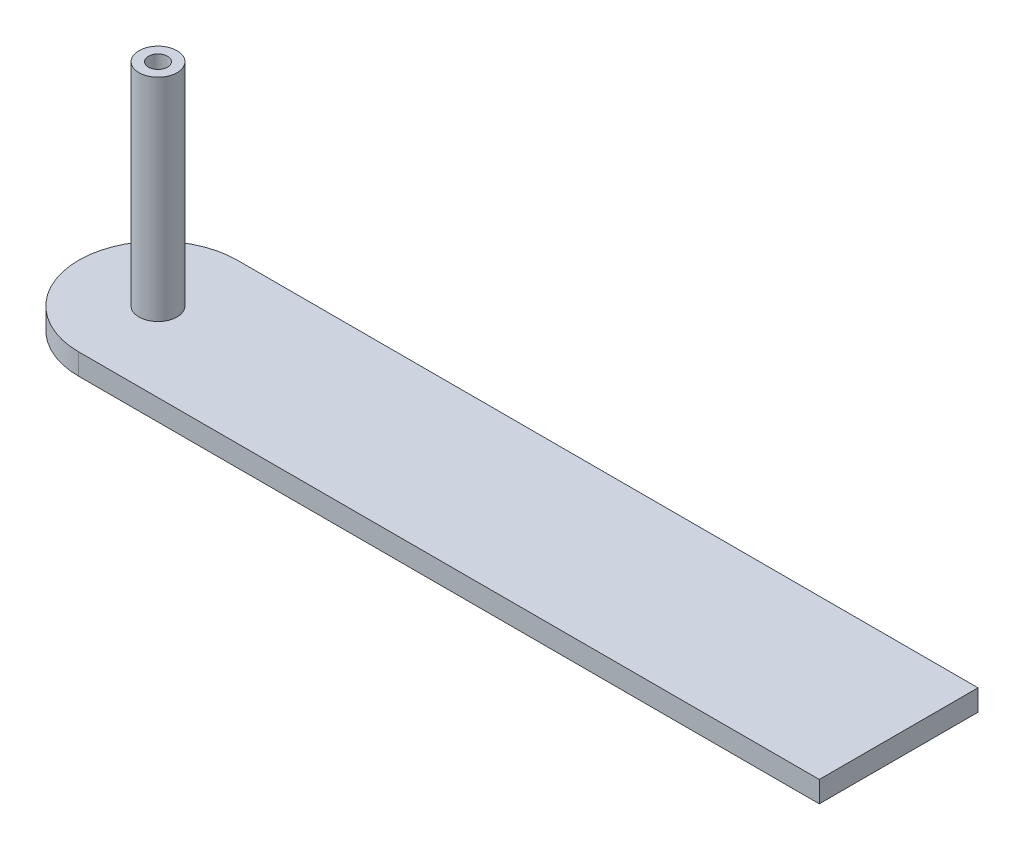
from build123d import *

# Parameters (mm, degrees)
SKETCH1_W           = 70
SKETCH1_H           = 15
BOSS_EXTRUDE1_DEPTH = 2
BOSS_EXTRUDE2_START = -2
SKETCH2_R           = 7.5
BOSS_EXTRUDE2_DEPTH = 2
SKETCH3_R           = 1.8
BOSS_EXTRUDE3_DEPTH = 20
SKETCH6_R           = 0.9
CUT_EXTRUDE1_DEPTH  = 6.5


with BuildPart() as part:
    # Sketch1 → Boss-Extrude1 (new body)
    with BuildSketch(Plane(origin=(0, 0, 0), x_dir=(1, 0, 0), z_dir=(0, 1, 0))):
        with Locations((35, 7.5)):
            Rectangle(SKETCH1_W, SKETCH1_H)
    extrude(amount=BOSS_EXTRUDE1_DEPTH)

    # Sketch2 → Boss-Extrude2 (add)
    with BuildSketch(Plane(origin=(0, 2, 0), x_dir=(1, 0, 0), z_dir=(0, 1, 0)).offset(BOSS_EXTRUDE2_START)):
        with Locations((0, 7.5)):
            Circle(SKETCH2_R)
    extrude(amount=BOSS_EXTRUDE2_DEPTH)

    # Sketch3 → Boss-Extrude3 (add)
    with BuildSketch(Plane(origin=(0, 2, 0), x_dir=(1, 0, 0), z_dir=(0, 1, 0))):
        with Locations((0, 7.5)):
            Circle(SKETCH3_R)
    extrude(amount=BOSS_EXTRUDE3_DEPTH)

    # Sketch6 → Cut-Extrude1 (cut)
    with BuildSketch(Plane(origin=(0, 22, 0), x_dir=(1, 0, 0), z_dir=(0, 1, 0))):
        with Locations((0, 7.5)):
            Circle(SKETCH6_R)
    extrude(amount=-CUT_EXTRUDE1_DEPTH, mode=Mode.SUBTRACT)


solid = part.part
